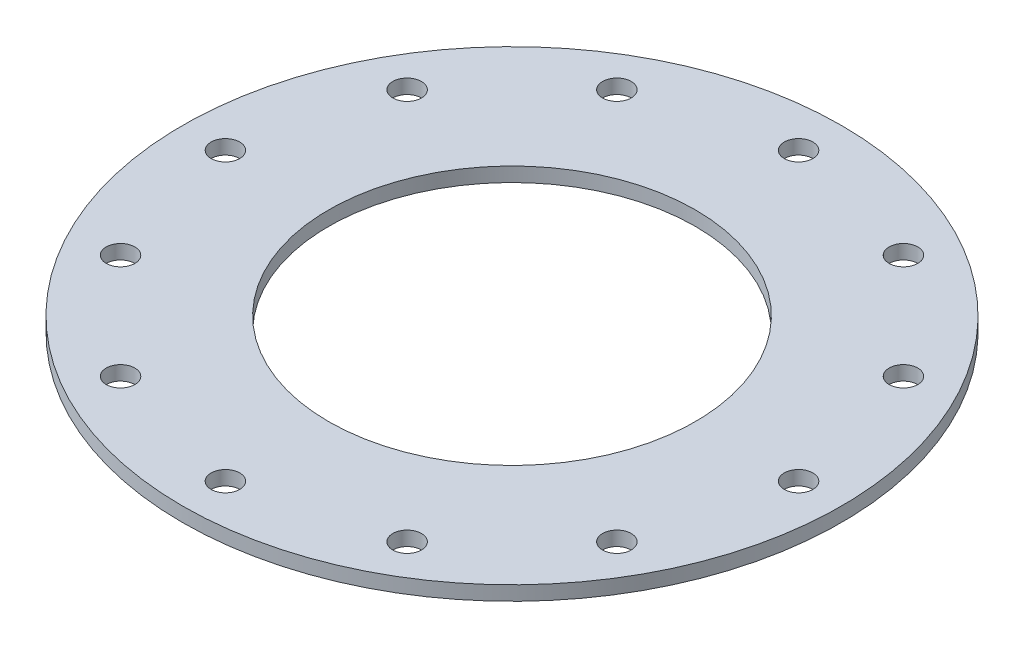
from build123d import *

# Parameters (mm, degrees)
SKETCH1_R           = 73.025
BOSS_EXTRUDE1_DEPTH = 3.175
SKETCH2_R           = 3.175
CUT_EXTRUDE1_DEPTH  = 4.175
SKETCH3_R           = 40.64
CUT_EXTRUDE2_DEPTH  = 4.175


with BuildPart() as part:
    # Sketch1 → Boss-Extrude1 (new body)
    with BuildSketch(Plane(origin=(0, 0, 0), x_dir=(1, 0, 0), z_dir=(0, 1, 0))):
        Circle(SKETCH1_R)
    extrude(amount=BOSS_EXTRUDE1_DEPTH)

    # Sketch2 → Cut-Extrude1 (cut, through all)
    with BuildSketch(Plane(origin=(0, 3.175, 0), x_dir=(1, 0, 0), z_dir=(0, 1, 0))):
        with Locations((63.5, 0)):
            Circle(SKETCH2_R)
        with Locations((54.99261314, -31.75)):
            Circle(SKETCH2_R)
        with Locations((31.75, -54.99261314)):
            Circle(SKETCH2_R)
        with Locations((0, -63.5)):
            Circle(SKETCH2_R)
        with Locations((-31.75, -54.99261314)):
            Circle(SKETCH2_R)
        with Locations((-54.99261314, -31.75)):
            Circle(SKETCH2_R)
        with Locations((-63.5, 0)):
            Circle(SKETCH2_R)
        with Locations((-54.99261314, 31.75)):
            Circle(SKETCH2_R)
        with Locations((-31.75, 54.99261314)):
            Circle(SKETCH2_R)
        with Locations((0, 63.5)):
            Circle(SKETCH2_R)
        with Locations((31.75, 54.99261314)):
            Circle(SKETCH2_R)
        with Locations((54.99261314, 31.75)):
            Circle(SKETCH2_R)
    extrude(amount=-CUT_EXTRUDE1_DEPTH, mode=Mode.SUBTRACT)

    # Sketch3 → Cut-Extrude2 (cut, through all)
    with BuildSketch(Plane(origin=(0, 3.175, 0), x_dir=(1, 0, 0), z_dir=(0, 1, 0))):
        Circle(SKETCH3_R)
    extrude(amount=-CUT_EXTRUDE2_DEPTH, mode=Mode.SUBTRACT)


solid = part.part
